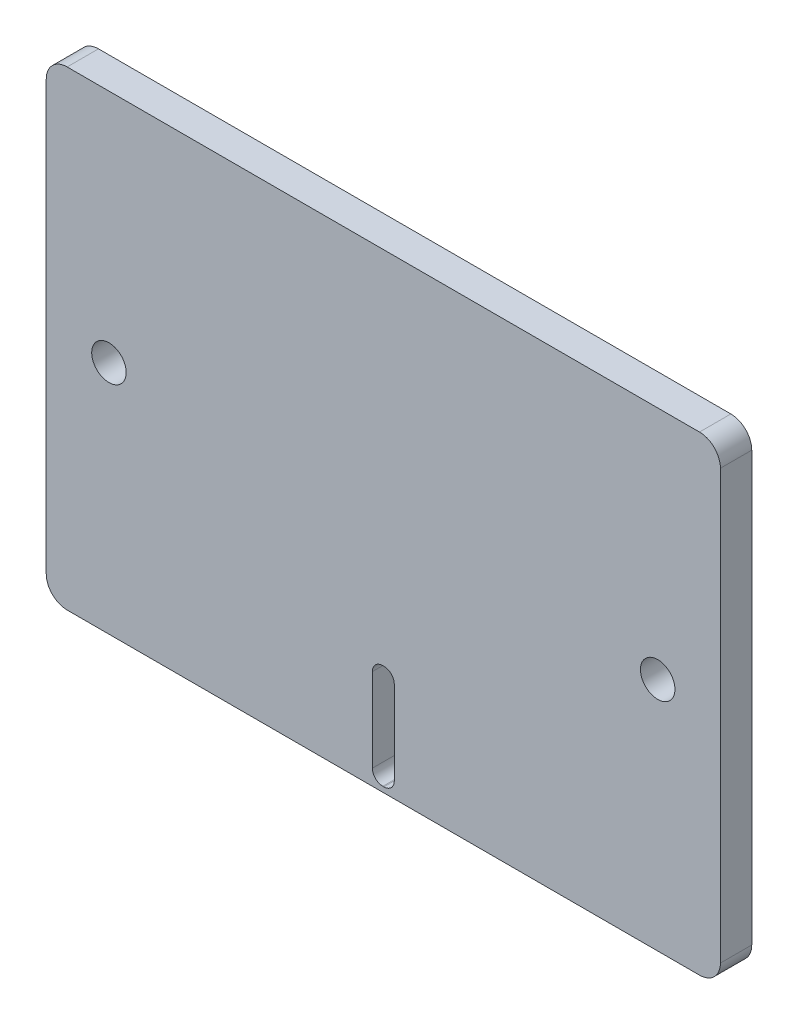
from build123d import *

# Parameters (mm, degrees)
SKETCH_1_W          = 64.5
SKETCH_1_H          = 45
EXTRUDE_1_DEPTH     = 3
SKETCH_6_W          = 12
SKETCH_6_H          = 10
EXTRUDE_4_DEPTH     = 3
FILLET_1_R          = 2
SKETCH_7_R          = 1.65
CUT_EXTRUDE_3_DEPTH = 6
SKETCH_9_W          = 6
SKETCH_9_H          = 14
CUT_EXTRUDE_4_DEPTH = 10
SKETCH_8_R          = 1.65
CUT_EXTRUDE_5_DEPTH = 10
SKETCH_10_W         = 2.1
SKETCH_10_H         = 10
CUT_EXTRUDE_6_DEPTH = 10
FILLET_2_R          = 1


with BuildPart() as part:
    # 草图1 → 凸台-拉伸1 (new body)
    with BuildSketch(Plane.XY):
        Rectangle(SKETCH_1_W, SKETCH_1_H)
    extrude(amount=EXTRUDE_1_DEPTH)

    # 草图6 → 凸台-拉伸4 (add)
    with BuildSketch(Plane.XY.offset(3)):
        with Locations((32.25, 0)):
            Rectangle(SKETCH_6_W, SKETCH_6_H)
        with Locations((-32.25, 0)):
            Rectangle(SKETCH_6_W, SKETCH_6_H)
    extrude(amount=-EXTRUDE_4_DEPTH)

    # 圆角1
    fillet_1_edges = [part.edges().sort_by_distance(p)[0] for p in [
        (38.25, -5, 1.5),
        (32.25, 5, 1.5),
        (32.25, -5, 1.5),
        (38.25, 5, 1.5),
        (-38.25, 5, 1.5),
        (-32.25, 5, 1.5),
        (-38.25, -5, 1.5),
        (-32.25, -5, 1.5),
        (32.25, -22.5, 1.5),
        (-32.25, -22.5, 1.5),
        (-32.25, 22.5, 1.5),
        (32.25, 22.5, 1.5),
    ]]
    fillet(fillet_1_edges, radius=FILLET_1_R)

    # 草图7 → 切除-拉伸3 (cut)
    with BuildSketch(Plane.XY.offset(3)):
        with Locations((-35.25, 0)):
            Circle(SKETCH_7_R)
        with Locations((35.25, 0)):
            Circle(SKETCH_7_R)
    extrude(amount=-CUT_EXTRUDE_3_DEPTH, mode=Mode.SUBTRACT)

    # 草图9 → 切除-拉伸4 (cut)
    with BuildSketch(Plane.XY.offset(3)):
        with Locations((-35.25, 0)):
            Rectangle(SKETCH_9_W, SKETCH_9_H)
        with Locations((35.25, 0)):
            Rectangle(SKETCH_9_W, SKETCH_9_H)
    extrude(amount=-CUT_EXTRUDE_4_DEPTH, mode=Mode.SUBTRACT)

    # 草图8 → 切除-拉伸5 (cut)
    with BuildSketch(Plane.XY.offset(3)):
        with Locations((-26.25, 0)):
            Circle(SKETCH_8_R)
        with Locations((26.25, 0)):
            Circle(SKETCH_8_R)
    extrude(amount=-CUT_EXTRUDE_5_DEPTH, mode=Mode.SUBTRACT)

    # 草图10 → 切除-拉伸6 (cut)
    with BuildSketch(Plane.XY.offset(3)):
        with Locations((0, -17)):
            Rectangle(SKETCH_10_W, SKETCH_10_H)
    extrude(amount=-CUT_EXTRUDE_6_DEPTH, mode=Mode.SUBTRACT)

    # 圆角2
    fillet_2_edges = [part.edges().sort_by_distance(p)[0] for p in [
        (1.05, -12, 1.5),
        (1.05, -22, 1.5),
        (-1.05, -22, 1.5),
        (-1.05, -12, 1.5),
    ]]
    fillet(fillet_2_edges, radius=FILLET_2_R)


solid = part.part
